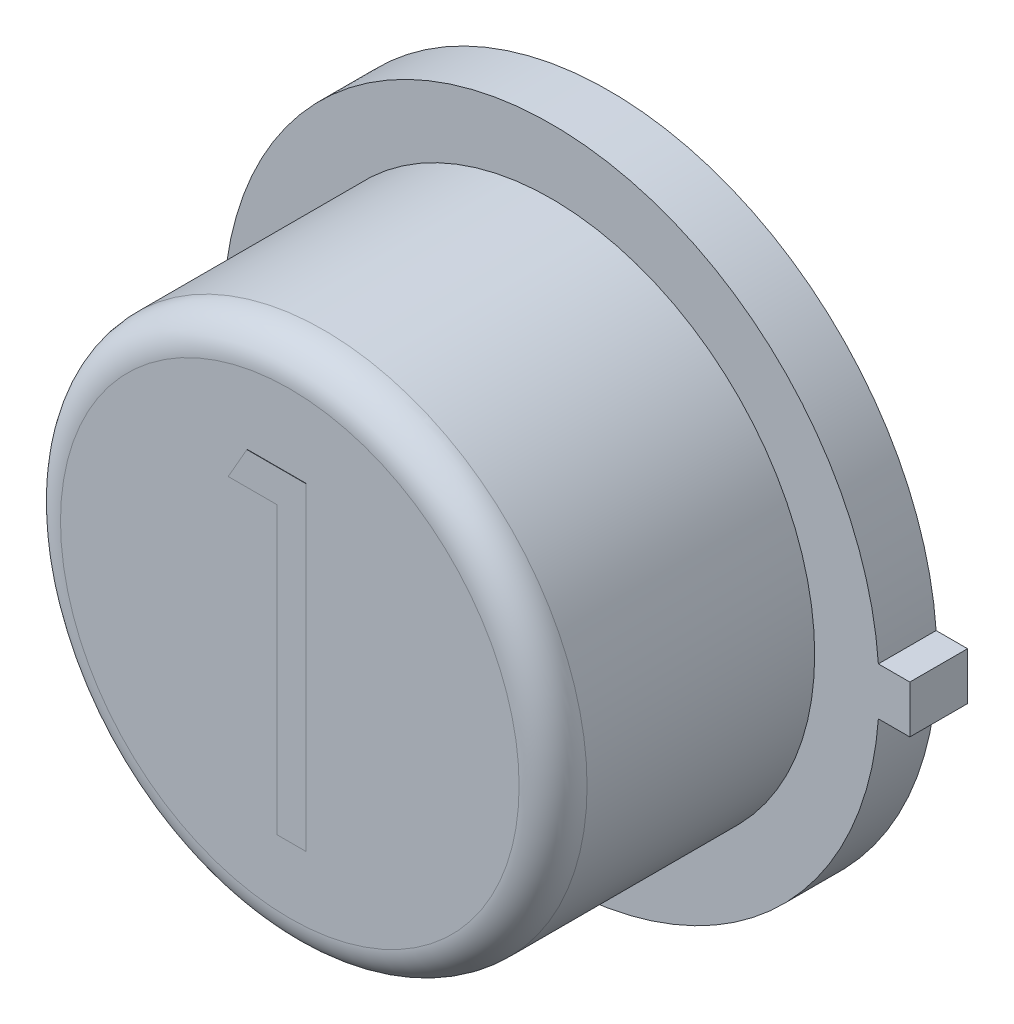
from build123d import *

# Parameters (mm, degrees)
BOSS_EXTRUDE1_DEPTH = 0.4318
SKETCH2_R           = 1.9685
BOSS_EXTRUDE2_DEPTH = 1.9558
SKETCH3_R           = 1.757566481
BOSS_EXTRUDE3_DEPTH = 0.00254
FILLET1_R           = 0.254
BOSS_EXTRUDE4_DEPTH = 0.00254


with BuildPart() as part:
    # Sketch1 → Boss-Extrude1 (new body)
    with BuildSketch(Plane.XY):
        with BuildLine():
            Line((2.6797, 0.1778), (2.4511, 0.1778))
            Line((2.4511, 0.1778), (2.44464279, 0.1778))
            ThreePointArc((2.44464279, 0.1778), (-2.4511, 0), (2.44464279, -0.1778))
            Line((2.44464279, -0.1778), (2.4511, -0.1778))
            Line((2.4511, -0.1778), (2.6797, -0.1778))
            Line((2.6797, -0.1778), (2.6797, 0.1778))
        make_face()
    extrude(amount=BOSS_EXTRUDE1_DEPTH)

    # Sketch2 → Boss-Extrude2 (add)
    with BuildSketch(Plane.XY.offset(0.4318)):
        Circle(SKETCH2_R)
    extrude(amount=BOSS_EXTRUDE2_DEPTH)

    # Sketch3 → Boss-Extrude3 (add)
    with BuildSketch(Plane(origin=(0, 0, 0), x_dir=(-1, 0, 0), z_dir=(0, 0, -1))):
        Circle(SKETCH3_R)
    extrude(amount=BOSS_EXTRUDE3_DEPTH)

    # Fillet1
    fillet1_edges = [part.edges().sort_by_distance(p)[0] for p in [
        (-1.9685, 0, 2.3876),
    ]]
    fillet(fillet1_edges, radius=FILLET1_R)

    # Sketch4 → Boss-Extrude4 (add)
    with BuildSketch(Plane.XY.offset(2.3876)):
        Polygon((-0.318167819, 1.163108793), (0.122115385, 1.163108793), (0.122115385, -1.218141207), (-0.091586538, -1.218141207), (-0.091586538, 0.918878024), (-0.457932692, 0.918878024), align=None)
    extrude(amount=BOSS_EXTRUDE4_DEPTH)


solid = part.part
